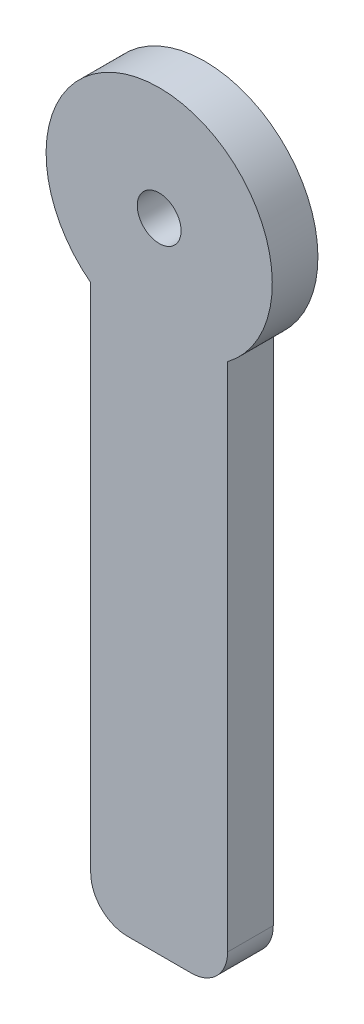
from build123d import *

# Parameters (mm, degrees)
BOSS_EXTRUDE1_DEPTH = 3.175
SKETCH2_R           = 1.524
CUT_EXTRUDE1_DEPTH  = 3.175


with BuildPart() as part:
    # Sketch1 → Boss-Extrude1 (new body)
    with BuildSketch(Plane.XY):
        with BuildLine():
            Line((-2.54, 0), (-6.985, 0))
            ThreePointArc((-6.985, 0), (-8.781051224, 0.743948776), (-9.525, 2.54))
            Line((-9.525, 2.54), (-9.525, 38.1))
            ThreePointArc((-9.525, 38.1), (-4.7625, 52.231044912), (0, 38.1))
            Line((0, 38.1), (0, 2.54))
            ThreePointArc((0, 2.54), (-0.743948776, 0.743948776), (-2.54, 0))
        make_face()
    extrude(amount=BOSS_EXTRUDE1_DEPTH)

    # Sketch2 → Cut-Extrude1 (cut)
    with BuildSketch(Plane.XY.offset(3.175)):
        with Locations((-4.7625, 44.362984272)):
            Circle(SKETCH2_R)
    extrude(amount=-CUT_EXTRUDE1_DEPTH, mode=Mode.SUBTRACT)


solid = part.part
